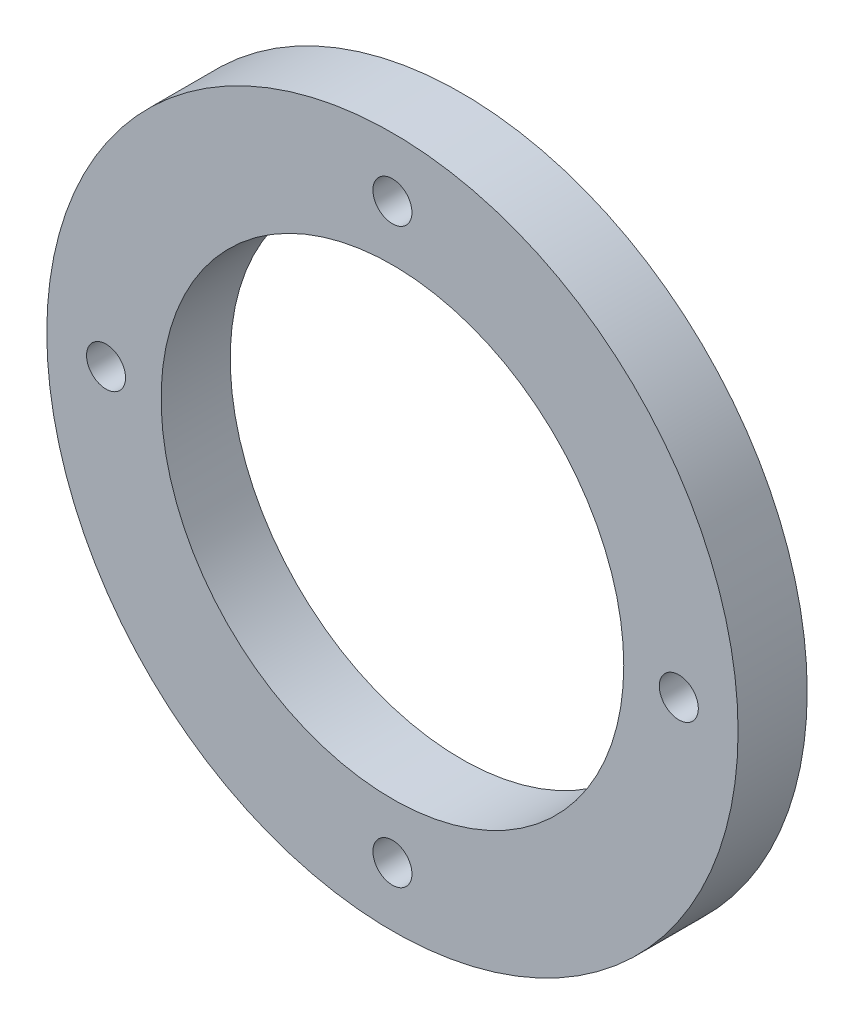
from build123d import *

# Parameters (mm, degrees)
SKETCH1_R           = 35
SKETCH1_R_2         = 23.425
SKETCH1_R_3         = 1.975
BOSS_EXTRUDE1_DEPTH = 5
SKETCH4_R           = 35
SKETCH4_R_2         = 23.425
SKETCH4_R_3         = 1.975
BOSS_EXTRUDE3_DEPTH = 2


with BuildPart() as part:
    # Sketch1 → Boss-Extrude1 (new body)
    with BuildSketch(Plane.XY):
        Circle(SKETCH1_R)
        Circle(SKETCH1_R_2, mode=Mode.SUBTRACT)
        with Locations((0, 29)):
            Circle(SKETCH1_R_3, mode=Mode.SUBTRACT)
        with Locations((29, 0)):
            Circle(SKETCH1_R_3, mode=Mode.SUBTRACT)
        with Locations((0, -29)):
            Circle(SKETCH1_R_3, mode=Mode.SUBTRACT)
        with Locations((-29, 0)):
            Circle(SKETCH1_R_3, mode=Mode.SUBTRACT)
    extrude(amount=BOSS_EXTRUDE1_DEPTH)

    # Sketch4 → Boss-Extrude3 (add)
    with BuildSketch(Plane.XY.offset(5)):
        Circle(SKETCH4_R)
        Circle(SKETCH4_R_2, mode=Mode.SUBTRACT)
        with Locations((0, 29)):
            Circle(SKETCH4_R_3, mode=Mode.SUBTRACT)
        with Locations((29, 0)):
            Circle(SKETCH4_R_3, mode=Mode.SUBTRACT)
        with Locations((0, -29)):
            Circle(SKETCH4_R_3, mode=Mode.SUBTRACT)
        with Locations((-29, 0)):
            Circle(SKETCH4_R_3, mode=Mode.SUBTRACT)
    extrude(amount=BOSS_EXTRUDE3_DEPTH)


solid = part.part
